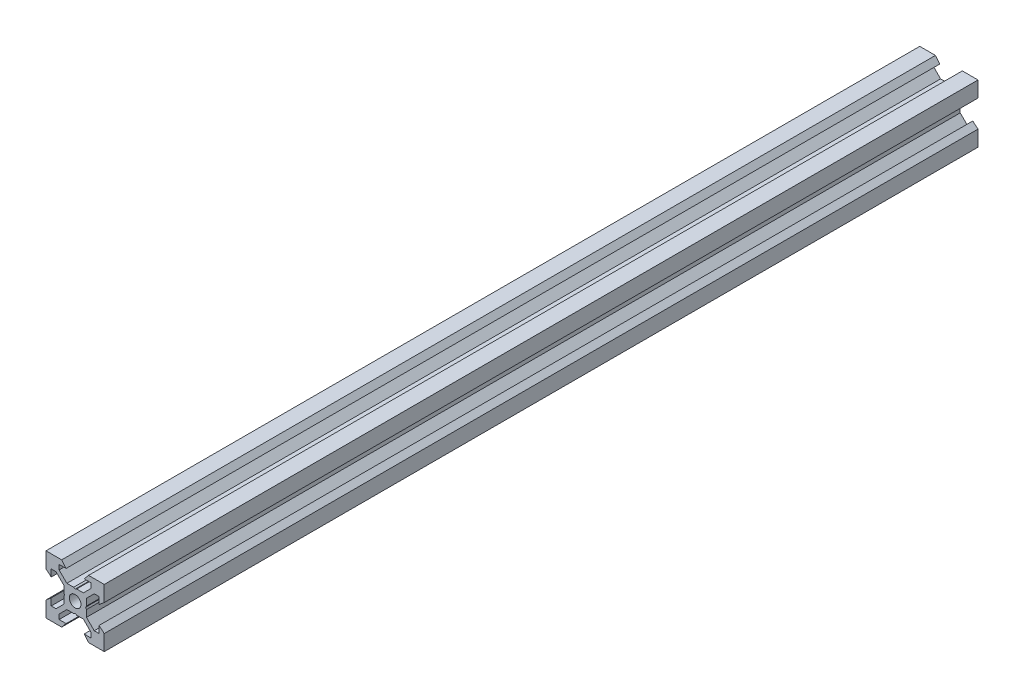
from build123d import *

# Parameters (mm, degrees)
SKETCH1_R           = 2
BOSS_EXTRUDE1_DEPTH = 150


with BuildPart() as part:
    # Sketch1 → Boss-Extrude1 (new body, symmetric)
    with BuildSketch(Plane.XY):
        Polygon((10, 10), (10, 4.610379336), (8.2, 3.1), (8.2, 5.5), (6.560660172, 5.5), (3.9, 2.839339828), (3.9, 0.519615242), (3.6, 0), (3.9, -0.519615242), (3.9, -2.839339828), (6.560660172, -5.5), (8.2, -5.5), (8.2, -3.1), (10, -4.610379336), (10, -10), (4.610379336, -10), (3.1, -8.2), (5.5, -8.2), (5.5, -6.560660172), (2.839339828, -3.9), (0.519615242, -3.9), (0, -3.6), (-0.519615242, -3.9), (-2.839339828, -3.9), (-5.5, -6.560660172), (-5.5, -8.2), (-3.1, -8.2), (-4.610379336, -10), (-10, -10), (-10, -4.610379336), (-8.2, -3.1), (-8.2, -5.5), (-6.560660172, -5.5), (-3.9, -2.839339828), (-3.9, -0.519615242), (-3.6, 0), (-3.9, 0.519615242), (-3.9, 2.839339828), (-6.560660172, 5.5), (-8.2, 5.5), (-8.2, 3.1), (-10, 4.610379336), (-10, 10), (-4.610379336, 10), (-3.1, 8.2), (-5.5, 8.2), (-5.5, 6.560660172), (-2.839339828, 3.9), (-0.519615242, 3.9), (0, 3.6), (0.519615242, 3.9), (2.839339828, 3.9), (5.5, 6.560660172), (5.5, 8.2), (3.1, 8.2), (4.610379336, 10), align=None)
        Circle(SKETCH1_R, mode=Mode.SUBTRACT)
    extrude(amount=BOSS_EXTRUDE1_DEPTH, both=True)


solid = part.part
